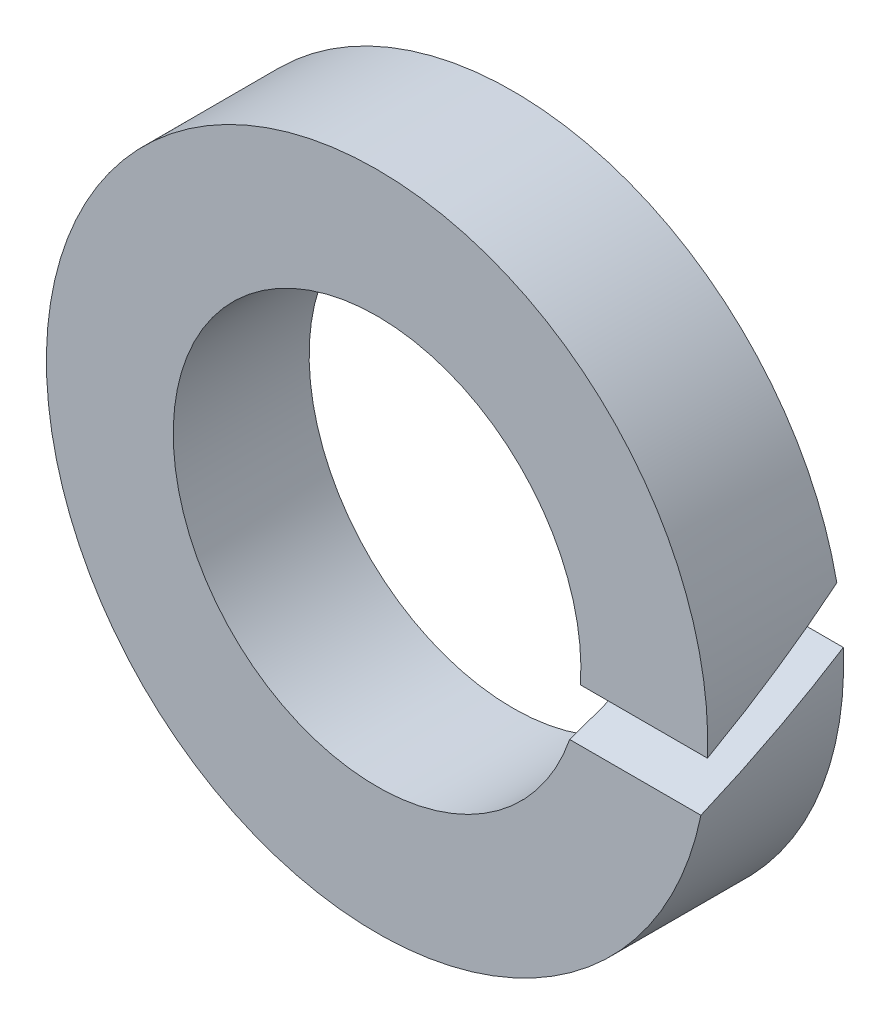
from build123d import *

# Parameters (mm, degrees)
ESQUISSE1_R             = 3.65
ESQUISSE1_R_2           = 2.25
BASE_EXTRUSION_DEPTH    = 1.5
ENL_V_MAT_EXTRU_1_DEPTH = 6.375406961


with BuildPart() as part:
    # Esquisse1 → Base-Extrusion (new body)
    with BuildSketch(Plane.XY):
        Circle(ESQUISSE1_R)
        Circle(ESQUISSE1_R_2, mode=Mode.SUBTRACT)
    extrude(amount=BASE_EXTRUSION_DEPTH)

    # Esquisse2 → Enlèv. mat.-Extru.1 (cut, through all)
    with BuildSketch(Plane(origin=(0, 0, 0), x_dir=(0, 0, -1), z_dir=(1, 0, 0))):
        Polygon((-1.5, -0.154321058), (0, 0.735714302), (0, 0.154321058), (-1.5, -0.735714302), align=None)
    extrude(amount=ENL_V_MAT_EXTRU_1_DEPTH, mode=Mode.SUBTRACT)


solid = part.part
